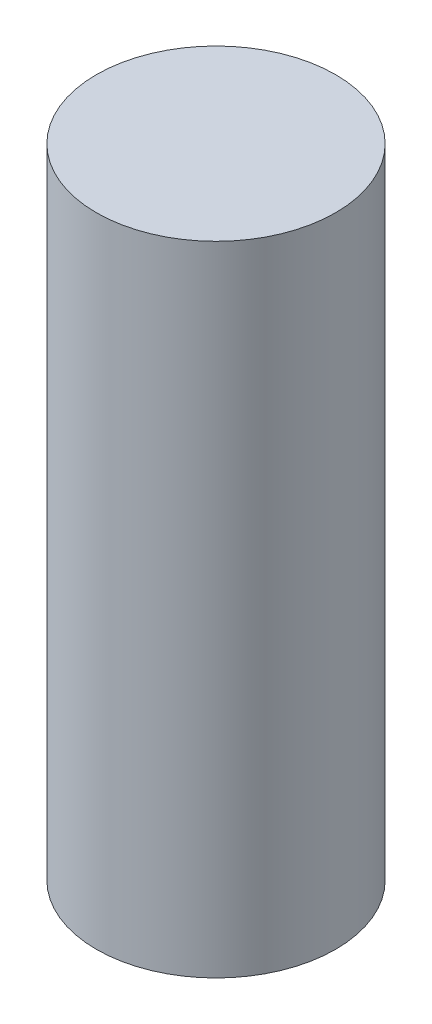
from build123d import *

# Parameters (mm, degrees)
SKETCH1_R           = 6
BOSS_EXTRUDE1_DEPTH = 32


with BuildPart() as part:
    # Sketch1 → Boss-Extrude1 (new body)
    with BuildSketch(Plane(origin=(0, 0, 0), x_dir=(1, 0, 0), z_dir=(0, 1, 0))):
        Circle(SKETCH1_R)
    extrude(amount=BOSS_EXTRUDE1_DEPTH)


solid = part.part
